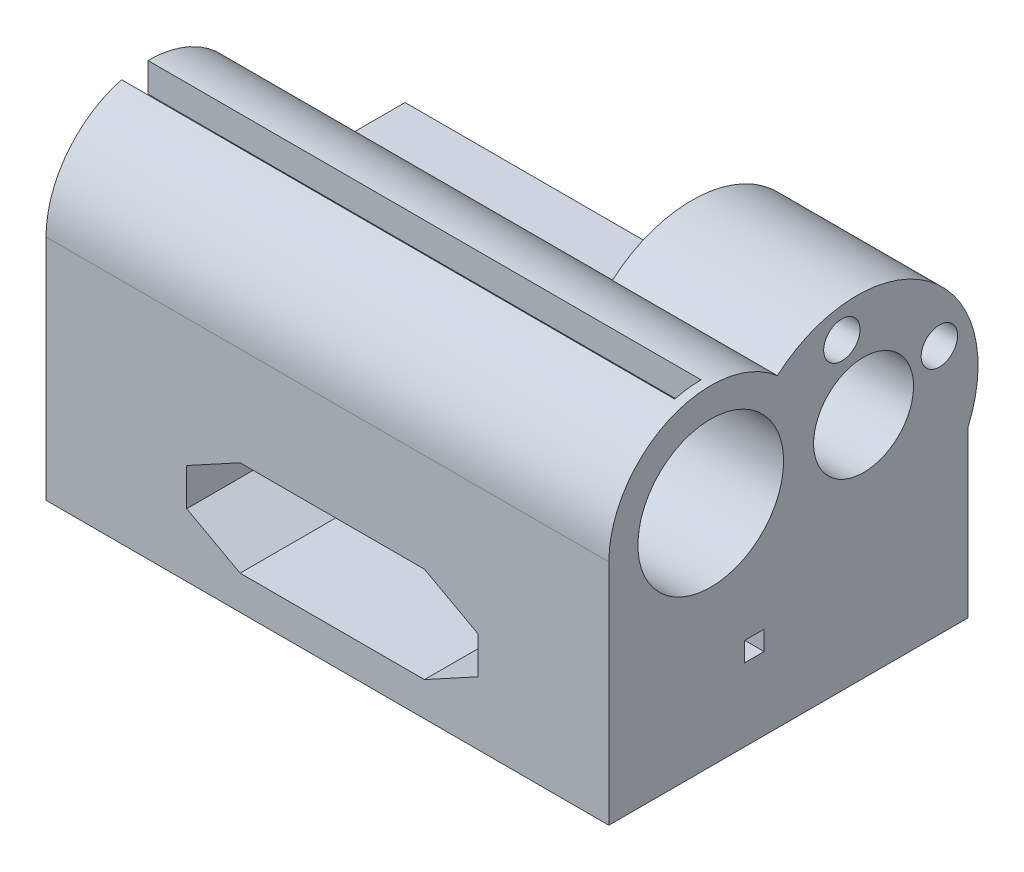
from build123d import *

# Parameters (mm, degrees)
SKETCH2_W           = 58
SKETCH2_H           = 37
BOSS_EXTRUDE1_DEPTH = 17
BOSS_EXTRUDE2_DEPTH = 58
SKETCH4_R           = 12.5
BOSS_EXTRUDE3_DEPTH = 17
CUT_EXTRUDE1_DEPTH  = 38
SKETCH6_R           = 4.076
CUT_EXTRUDE2_DEPTH  = 23
SKETCH7_R           = 7.5075
SKETCH7_R_2         = 5.15
CUT_EXTRUDE3_DEPTH  = 59
SKETCH8_R           = 1.875
CUT_EXTRUDE4_DEPTH  = 59
SKETCH12_W          = 2
SKETCH12_H          = 2
CUT_EXTRUDE6_DEPTH  = 8
CUT_EXTRUDE7_DEPTH  = 57
SKETCH14_R          = 1.5
CUT_EXTRUDE8_DEPTH  = 35.5


with BuildPart() as part:
    # Sketch2 → Boss-Extrude1 (new body)
    with BuildSketch(Plane(origin=(0, 0, 0), x_dir=(1, 0, 0), z_dir=(0, 1, 0))):
        Rectangle(SKETCH2_W, SKETCH2_H)
    extrude(amount=BOSS_EXTRUDE1_DEPTH)

    # Sketch3 → Boss-Extrude2 (add)
    with BuildSketch(Plane(origin=(29, 0, 0), x_dir=(0, 0, -1), z_dir=(1, 0, 0))):
        with BuildLine():
            Line((-18.5, 23.5), (-18.5, 17))
            Line((-18.5, 17), (2.5, 17))
            Line((2.5, 17), (2.5, 23.5))
            ThreePointArc((2.5, 23.5), (-8, 34), (-18.5, 23.5))
        make_face()
    extrude(amount=-BOSS_EXTRUDE2_DEPTH)

    # Sketch4 → Boss-Extrude3 (add)
    with BuildSketch(Plane(origin=(29, 0, 0), x_dir=(0, 0, -1), z_dir=(1, 0, 0))):
        with Locations((7.043560763, 22)):
            Circle(SKETCH4_R)
    extrude(amount=-BOSS_EXTRUDE3_DEPTH)

    # Sketch5 → Cut-Extrude1 (cut, through all)
    with BuildSketch(Plane(origin=(0, 0, -18.5), x_dir=(-1, 0, 0), z_dir=(0, 0, -1))):
        Polygon((-15.5, 6.5), (-15.5, 10.35), (-10, 13.35), (9, 13.35), (14.5, 10.357), (14.5, 6.5), (9, 3.5), (-10, 3.5), align=None)
    extrude(amount=-CUT_EXTRUDE1_DEPTH, mode=Mode.SUBTRACT)

    # Sketch6 → Cut-Extrude2 (cut)
    with BuildSketch(Plane(origin=(0, 0, -18.5), x_dir=(-1, 0, 0), z_dir=(0, 0, -1))):
        with Locations((-23, 8.5)):
            Circle(SKETCH6_R)
        with Locations((22, 8.5)):
            Circle(SKETCH6_R)
    extrude(amount=-CUT_EXTRUDE2_DEPTH, mode=Mode.SUBTRACT)

    # Sketch7 → Cut-Extrude3 (cut, through all)
    with BuildSketch(Plane(origin=(29, 0, 0), x_dir=(0, 0, -1), z_dir=(1, 0, 0))):
        with Locations((-8, 23.5)):
            Circle(SKETCH7_R)
        with Locations((7.7501439, 23.5)):
            Circle(SKETCH7_R_2)
    extrude(amount=-CUT_EXTRUDE3_DEPTH, mode=Mode.SUBTRACT)

    # Sketch8 → Cut-Extrude4 (cut, through all)
    with BuildSketch(Plane(origin=(29, 0, 0), x_dir=(0, 0, -1), z_dir=(1, 0, 0))):
        with Locations((5.509653427, 31.309982551)):
            Circle(SKETCH8_R)
        with Locations((15.560126451, 25.740490473)):
            Circle(SKETCH8_R)
    extrude(amount=-CUT_EXTRUDE4_DEPTH, mode=Mode.SUBTRACT)

    # Sketch12 → Cut-Extrude6 (cut)
    with BuildSketch(Plane.ZY.offset(29)):
        with Locations((3.5, 8.5)):
            Rectangle(SKETCH12_W, SKETCH12_H)
    cut_extrude6 = extrude(amount=-CUT_EXTRUDE6_DEPTH, mode=Mode.SUBTRACT)

    # Mirror1: Cut-Extrude6 across plane
    add(cut_extrude6.mirror(Plane(origin=(0, 0, 0), x_dir=(0, 0, 1), z_dir=(1, 0, 0))), mode=Mode.SUBTRACT)

    # Sketch13 → Cut-Extrude7 (cut)
    with BuildSketch(Plane.ZY.offset(29)):
        with BuildLine():
            ThreePointArc((8, 31.0075), (8.979925388, 30.943272297), (9.943083981, 30.751688141))
            Line((9.943083981, 30.751688141), (10.717599974, 33.642221176))
            ThreePointArc((10.717599974, 33.642221176), (9.370525018, 33.910171044), (8, 34))
            Line((8, 34), (8, 31.0075))
        make_face()
    extrude(amount=-CUT_EXTRUDE7_DEPTH, mode=Mode.SUBTRACT)

    # Sketch14 → Cut-Extrude8 (cut, through all)
    with BuildSketch(Plane.XZ):
        with Locations((0.5, -11.5)):
            Circle(SKETCH14_R)
    extrude(amount=-CUT_EXTRUDE8_DEPTH, mode=Mode.SUBTRACT)


solid = part.part
